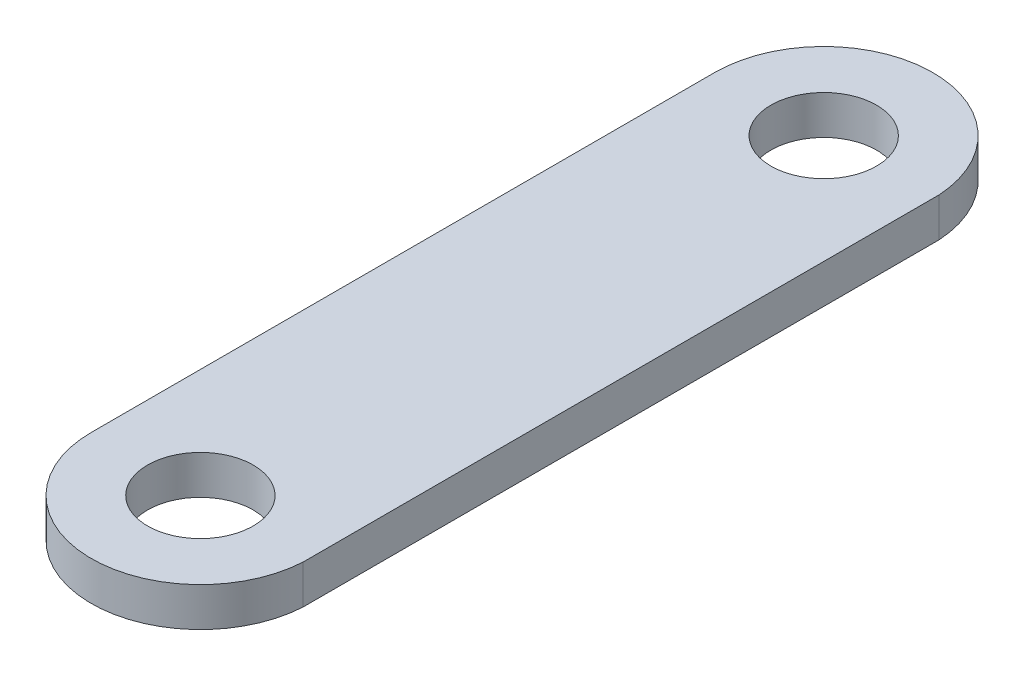
from build123d import *

# Parameters (mm, degrees)
SKETCH1_R           = 2.15265
BOSS_EXTRUDE1_DEPTH = 1.5875


with BuildPart() as part:
    # Sketch1 → Boss-Extrude1 (new body)
    with BuildSketch(Plane(origin=(0, 0, 0), x_dir=(1, 0, 0), z_dir=(0, 1, 0))):
        with BuildLine():
            Line((-4.445, 12.7), (-4.445, -12.7))
            ThreePointArc((-4.445, -12.7), (-0.128082185, -17.146957756), (4.445, -12.963880894))
            Line((4.445, -12.963880894), (4.445, 12.963880894))
            ThreePointArc((4.445, 12.963880894), (-0.128082185, 17.146957756), (-4.445, 12.7))
        make_face()
        with Locations((0.003916374, 12.7)):
            Circle(SKETCH1_R, mode=Mode.SUBTRACT)
        with Locations((0.003916374, -12.7)):
            Circle(SKETCH1_R, mode=Mode.SUBTRACT)
    extrude(amount=BOSS_EXTRUDE1_DEPTH)


solid = part.part
